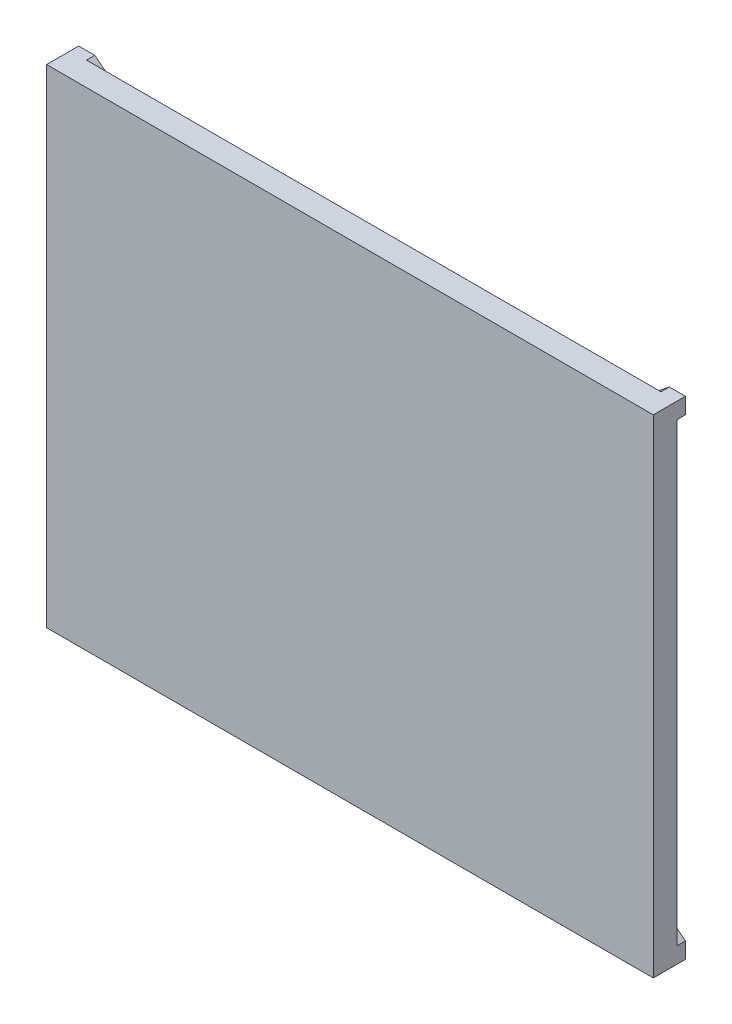
from build123d import *

# Parameters (mm, degrees)
SKETCH1_W           = 1020
SKETCH1_H           = 820
BOSS_EXTRUDE1_DEPTH = 40
BOSS_EXTRUDE2_DEPTH = 14


with BuildPart() as part:
    # Sketch1 → Boss-Extrude1 (new body)
    with BuildSketch(Plane.XY):
        Rectangle(SKETCH1_W, SKETCH1_H)
    extrude(amount=BOSS_EXTRUDE1_DEPTH)

    # Sketch2 → Boss-Extrude2 (add)
    with BuildSketch(Plane(origin=(0, 0, 0), x_dir=(-1, 0, 0), z_dir=(0, 0, -1))):
        Polygon((-482.961977854, 410), (510, -382.961977854), (510, -410), (482.961977854, -410), (-510, 382.961977854), (-510, 410), align=None)
    boss_extrude2 = extrude(amount=BOSS_EXTRUDE2_DEPTH)

    # Mirror1: Boss-Extrude2 across plane
    add(boss_extrude2.mirror(Plane.ZX))


solid = part.part
